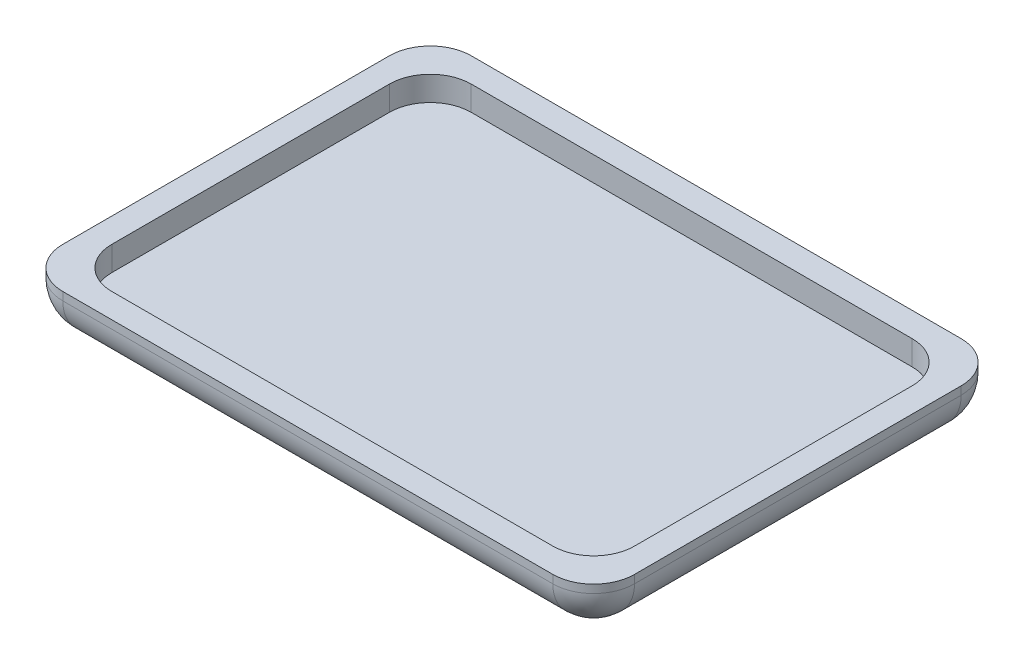
from build123d import *

# Parameters (mm, degrees)
SKETCH1_W           = 70
SKETCH1_H           = 50
BOSS_EXTRUDE1_DEPTH = 6
SHELL1_T            = -3
FILLET1_R           = 5
FILLET2_R           = 5
FILLET3_R           = 5
FILLET4_R           = 5
FILLET5_R           = 5
FILLET6_R           = 5
FILLET7_R           = 5
FILLET8_R           = 5
FILLET9_R           = 5


with BuildPart() as part:
    # Sketch1 → Boss-Extrude1 (new body)
    with BuildSketch(Plane(origin=(0, 0, 0), x_dir=(1, 0, 0), z_dir=(0, 1, 0))):
        Rectangle(SKETCH1_W, SKETCH1_H)
    extrude(amount=BOSS_EXTRUDE1_DEPTH)

    # Shell1
    shell1_openings = [part.faces().sort_by_distance(p)[0] for p in [
        (0, 6, 0),
    ]]
    offset(amount=SHELL1_T, openings=shell1_openings, kind=Kind.INTERSECTION)

    # Fillet1
    fillet1_edges = [part.edges().sort_by_distance(p)[0] for p in [
        (35, 3, 25),
    ]]
    fillet(fillet1_edges, radius=FILLET1_R)

    # Fillet2
    fillet2_edges = [part.edges().sort_by_distance(p)[0] for p in [
        (35, 3, -25),
    ]]
    fillet(fillet2_edges, radius=FILLET2_R)

    # Fillet3
    fillet3_edges = [part.edges().sort_by_distance(p)[0] for p in [
        (-35, 3, 25),
    ]]
    fillet(fillet3_edges, radius=FILLET3_R)

    # Fillet4
    fillet4_edges = [part.edges().sort_by_distance(p)[0] for p in [
        (-35, 3, -25),
    ]]
    fillet(fillet4_edges, radius=FILLET4_R)

    # Fillet5
    fillet5_edges = [part.edges().sort_by_distance(p)[0] for p in [
        (35, 0, 0),
        (0, 0, -25),
        (0, 0, 25),
        (-35, 0, 0),
    ]]
    fillet(fillet5_edges, radius=FILLET5_R)

    # Fillet6
    fillet6_edges = [part.edges().sort_by_distance(p)[0] for p in [
        (32, 4.5, 22),
    ]]
    fillet(fillet6_edges, radius=FILLET6_R)

    # Fillet7
    fillet7_edges = [part.edges().sort_by_distance(p)[0] for p in [
        (-32, 4.5, 22),
    ]]
    fillet(fillet7_edges, radius=FILLET7_R)

    # Fillet8
    fillet8_edges = [part.edges().sort_by_distance(p)[0] for p in [
        (-32, 4.5, -22),
    ]]
    fillet(fillet8_edges, radius=FILLET8_R)

    # Fillet9
    fillet9_edges = [part.edges().sort_by_distance(p)[0] for p in [
        (32, 4.5, -22),
    ]]
    fillet(fillet9_edges, radius=FILLET9_R)


solid = part.part
